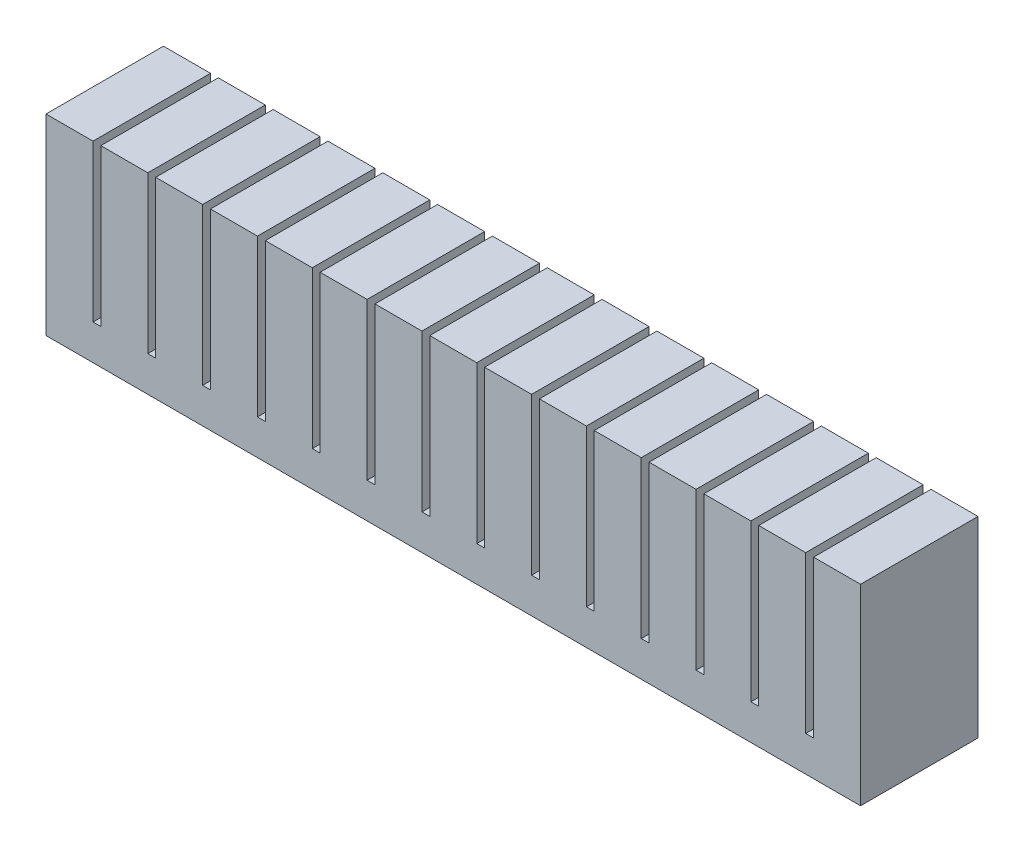
from build123d import *

# Parameters (mm, degrees)
BOSS_EXTRUDE1_DEPTH     = 7.5
LPATTERN1_COUNT         = 8
LPATTERN1_PITCH         = 7
LPATTERN1_COL_COUNT     = 8
LPATTERN1_COL_PITCH     = 7
SHELL2_T                = -1
SKETCH3_W               = 0.5
SKETCH3_H               = 4.5
CUT_EXTRUDE2_DEPTH      = 15
CUT_EXTRUDE2_DEPTH_BACK = 8.5
SKETCH4_W               = 13
SKETCH4_H               = 2.5
BOSS_EXTRUDE2_DEPTH     = 1
SKETCH5_W               = 13
SKETCH5_H               = 2.5
BOSS_EXTRUDE3_DEPTH     = 1
SKETCH8_W               = 6
SKETCH8_H               = 15
BOSS_EXTRUDE5_DEPTH     = 2
LPATTERN2_COUNT         = 15
LPATTERN2_PITCH         = 7


with BuildPart() as part:
    # Sketch1 → Boss-Extrude1 (new body, symmetric)
    with BuildSketch(Plane.XY):
        Polygon((0, 0), (-3.5, 0), (-3.5, 4.5), (-3, 4.5), (-3, 22.5), (3, 22.5), (3, 4.5), (3.5, 4.5), (3.5, 0), align=None)
    boss_extrude1 = extrude(amount=BOSS_EXTRUDE1_DEPTH, both=True)

    # LPattern1: Boss-Extrude1 ×8
    with Locations(*[(i * LPATTERN1_PITCH, 0, 0) for i in range(1, LPATTERN1_COUNT)]):
        add(boss_extrude1)

    # LPattern1 col: Boss-Extrude1 ×8
    with Locations(*[(-i * LPATTERN1_COL_PITCH, 0, 0) for i in range(1, LPATTERN1_COL_COUNT)]):
        add(boss_extrude1)

    # Shell2
    shell2_openings = [part.faces().sort_by_distance(p)[0] for p in [
        (52.5, 2.25, 0),
        (-52.5, 2.25, 0),
    ]]
    offset(amount=SHELL2_T, openings=shell2_openings, kind=Kind.INTERSECTION)

    # Sketch3 → Cut-Extrude2 (cut, two sides)
    with BuildSketch(Plane.XY) as cut_extrude2_sk:
        with Locations((-52.25, 2.25)):
            Rectangle(SKETCH3_W, SKETCH3_H)
        with Locations((52.25, 2.25)):
            Rectangle(SKETCH3_W, SKETCH3_H)
    extrude(amount=CUT_EXTRUDE2_DEPTH, mode=Mode.SUBTRACT)
    extrude(cut_extrude2_sk.sketch, amount=-CUT_EXTRUDE2_DEPTH_BACK, mode=Mode.SUBTRACT)

    # Sketch4 → Boss-Extrude2 (add)
    with BuildSketch(Plane.ZY.offset(52)):
        with Locations((0, 2.25)):
            Rectangle(SKETCH4_W, SKETCH4_H)
    extrude(amount=-BOSS_EXTRUDE2_DEPTH)

    # Sketch5 → Boss-Extrude3 (add)
    with BuildSketch(Plane(origin=(52, 0, 0), x_dir=(0, 0, -1), z_dir=(1, 0, 0))):
        with Locations((0, 2.25)):
            Rectangle(SKETCH5_W, SKETCH5_H)
    extrude(amount=-BOSS_EXTRUDE3_DEPTH)

    # Sketch8 → Boss-Extrude5 (add)
    with BuildSketch(Plane(origin=(0, 22.5, 0), x_dir=(1, 0, 0), z_dir=(0, 1, 0))):
        with Locations((-49, 0)):
            Rectangle(SKETCH8_W, SKETCH8_H)
    boss_extrude5 = extrude(amount=BOSS_EXTRUDE5_DEPTH)

    # LPattern2: Boss-Extrude5 ×15
    with Locations(*[(i * LPATTERN2_PITCH, 0, 0) for i in range(1, LPATTERN2_COUNT)]):
        add(boss_extrude5)


solid = part.part
